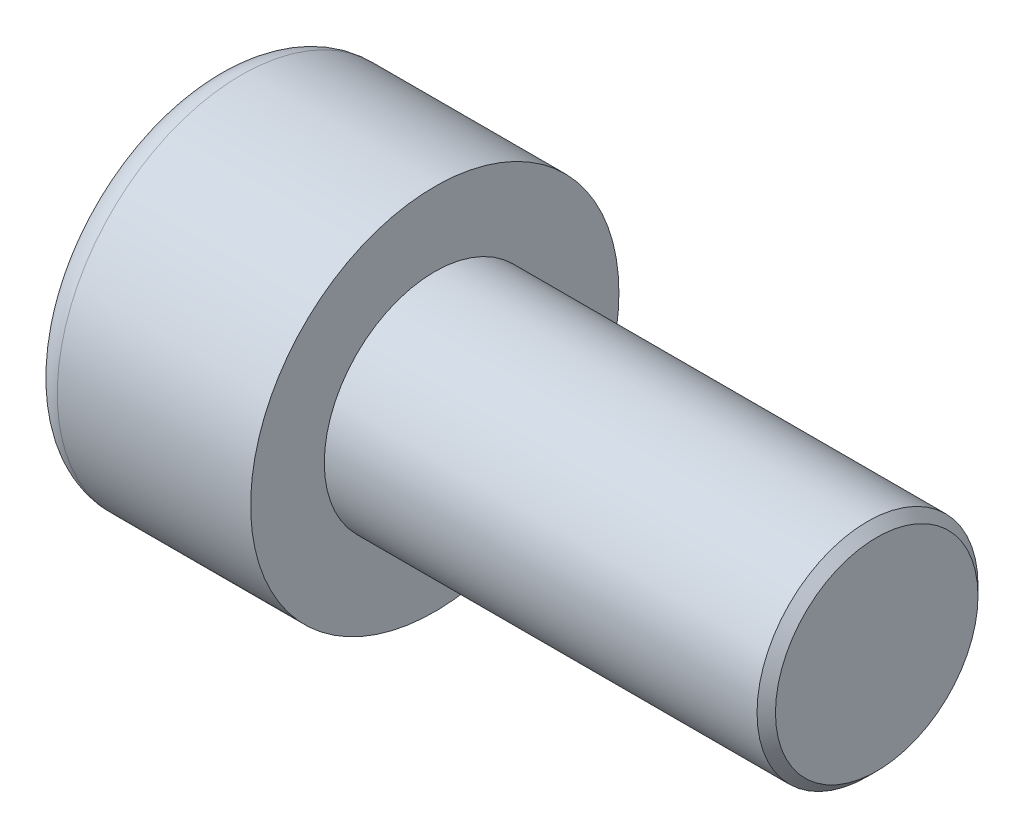
from build123d import *

# Parameters (mm, degrees)
SKETCH1_R           = 5
BASEHEAD_DEPTH      = 6
SKETCH2_R           = 3
BASEBODY_DEPTH      = 12
HEXAGONSOCKET_DEPTH = 3
TOPFILLET_R         = 0.75
CHAMFER1_SIZE       = 0.25


with BuildPart() as part:
    # Sketch1 → BaseHead (new body)
    with BuildSketch(Plane(origin=(0, 0, 0), x_dir=(0, 0, -1), z_dir=(1, 0, 0))):
        Circle(SKETCH1_R)
    extrude(amount=BASEHEAD_DEPTH)

    # Sketch2 → BaseBody (add)
    with BuildSketch(Plane(origin=(6, 0, 0), x_dir=(0, 0, -1), z_dir=(1, 0, 0))):
        Circle(SKETCH2_R)
    extrude(amount=BASEBODY_DEPTH)

    # Sketch3 → HexagonSocket (cut)
    with BuildSketch(Plane(origin=(0, 0, 0), x_dir=(0, 0, -1), z_dir=(1, 0, 0))):
        Polygon((2.886751346, 0), (1.443375673, 2.5), (-1.443375673, 2.5), (-2.886751346, 0), (-1.443375673, -2.5), (1.443375673, -2.5), align=None)
    extrude(amount=HEXAGONSOCKET_DEPTH, mode=Mode.SUBTRACT)

    # Sketch4 → Cut-Revolve1 (revolve, cut)
    with BuildSketch(Plane(origin=(-4.19613823, 0.75, 0), x_dir=(-1, 0, 0), z_dir=(0, 0, 1))):
        Polygon((-7.19613823, 3.25), (-8.639513903, 0.75), (-7.19613823, 0.75), align=None)
    revolve(axis=Axis((0.838992387, 0, 0), (-1, 0, 0)), mode=Mode.SUBTRACT)

    # TopFillet
    topfillet_edges = [part.edges().sort_by_distance(p)[0] for p in [
        (0, 0, 5),
    ]]
    fillet(topfillet_edges, radius=TOPFILLET_R)

    # Chamfer1
    chamfer1_edges = [part.edges().sort_by_distance(p)[0] for p in [
        (18, 0, 3),
    ]]
    chamfer(chamfer1_edges, length=CHAMFER1_SIZE)


solid = part.part
